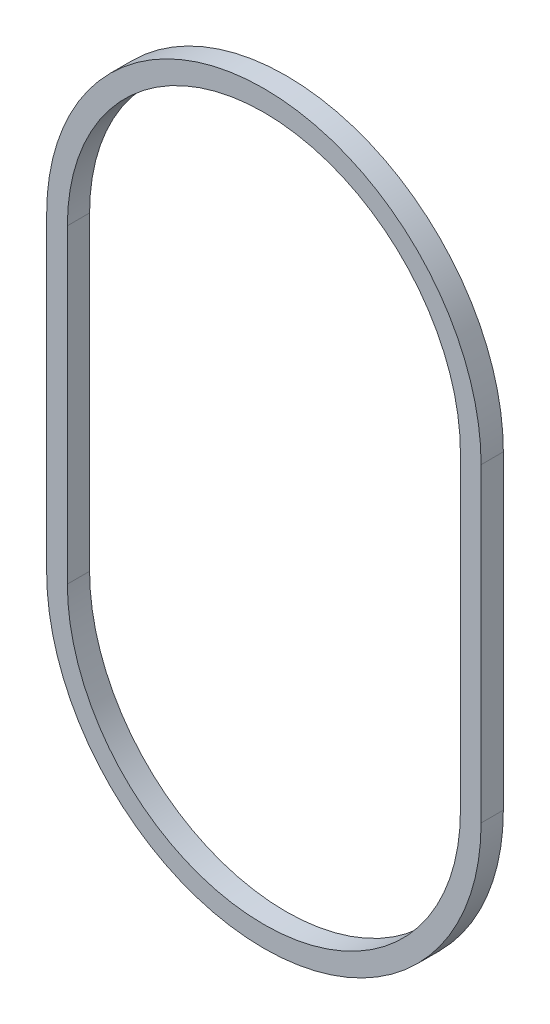
from build123d import *

# Parameters (mm, degrees)
EXTRUDE_THIN1_DEPTH = 1.075


with BuildPart() as part:
    # Sketch1 → Extrude-Thin1 (new body, symmetric)
    with BuildSketch(Plane.XY):
        with BuildLine():
            Line((21, 15), (21, -15))
            ThreePointArc((21, -15), (0, -36), (-21, -15))
            Line((-21, -15), (-21, 15))
            ThreePointArc((-21, 15), (0, 36), (21, 15))
        make_face()
        with BuildLine():
            Line((19, 15), (19, -15))
            ThreePointArc((19, -15), (0, -34), (-19, -15))
            Line((-19, -15), (-19, 15))
            ThreePointArc((-19, 15), (0, 34), (19, 15))
        make_face(mode=Mode.SUBTRACT)
    extrude(amount=EXTRUDE_THIN1_DEPTH, both=True)


solid = part.part
